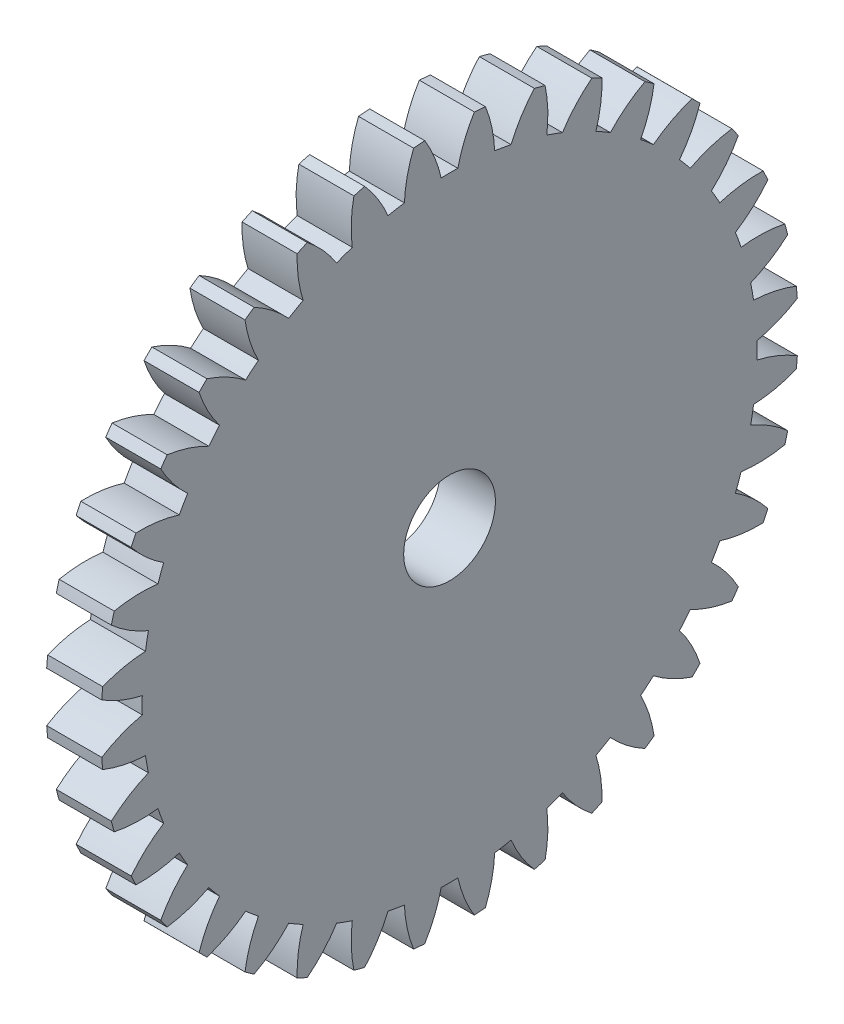
from build123d import *

# Parameters (mm, degrees)
BASPROSKE_W     = 3
BASPROSKE_H     = 19
TOOTHCUT_DEPTH  = 28.037011669
TEETHCUTS_COUNT = 36
TEETHCUTS_ANGLE = 350
BORSKE_R        = 2.5
BORE_DEPTH      = 50.0000508


with BuildPart() as part:
    # BasProSke → Base-Revolve (revolve)
    with BuildSketch(Plane(origin=(0, 0, 0), x_dir=(1, 0, 0), z_dir=(0, 1, 0)), mode=Mode.PRIVATE) as base_revolve_sk:
        with Locations((1.5, 9.5)):
            Rectangle(BASPROSKE_W, BASPROSKE_H)
    revolve(base_revolve_sk.sketch.rotate(Axis((-10, 0, 0), (1, 0, 0)), 180), axis=Axis((-10, 0, 0), (1, 0, 0)))

    # TooCutSke → ToothCut (cut, through all)
    with BuildSketch(Plane(origin=(0, 0, 0), x_dir=(0, 0, -1), z_dir=(1, 0, 0))):
        with BuildLine():
            ThreePointArc((0.454664826, 16.742827745), (0, 16.749), (-0.454664826, 16.742827745))
            ThreePointArc((-0.454664826, 16.742827745), (-0.817558311, 17.898033097), (-1.368909141, 18.976088452))
            ThreePointArc((-1.368909141, 18.976088452), (0, 19.0254), (1.368909141, 18.976088452))
            ThreePointArc((1.368909141, 18.976088452), (0.817558311, 17.898033097), (0.454664826, 16.742827745))
        make_face()
    toothcut = extrude(amount=TOOTHCUT_DEPTH, mode=Mode.SUBTRACT)

    # TeethCuts: ToothCut ×36 about axis
    teethcuts_axis = Axis((-10, 0, 0), (1, 0, 0))
    for i in range(1, TEETHCUTS_COUNT):
        add(toothcut.rotate(teethcuts_axis, i * TEETHCUTS_ANGLE / (TEETHCUTS_COUNT - 1)), mode=Mode.SUBTRACT)

    # BorSke → Bore (cut, symmetric)
    with BuildSketch(Plane(origin=(0, 0, 0), x_dir=(0, 0, -1), z_dir=(1, 0, 0))):
        with Locations(Location((0, 0, 0), (0, 0, 180))):
            Circle(BORSKE_R)
    extrude(amount=BORE_DEPTH, both=True, mode=Mode.SUBTRACT)


solid = part.part
